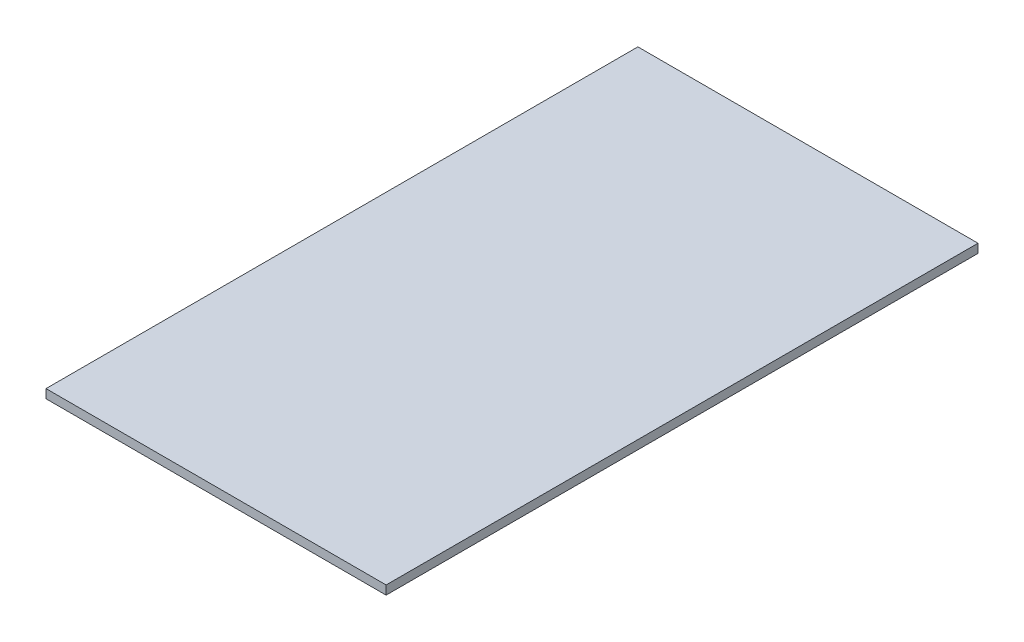
from build123d import *

# Parameters (mm, degrees)
ESQUISSE1_W        = 385
ESQUISSE1_H        = 670
BOSS_EXTRU_1_DEPTH = 10


with BuildPart() as part:
    # Esquisse1 → Boss.-Extru.1 (new body)
    with BuildSketch(Plane(origin=(0, 0, 0), x_dir=(1, 0, 0), z_dir=(0, 1, 0))):
        with Locations((104.554763419, -301.184437202)):
            Rectangle(ESQUISSE1_W, ESQUISSE1_H)
    extrude(amount=BOSS_EXTRU_1_DEPTH)


solid = part.part
